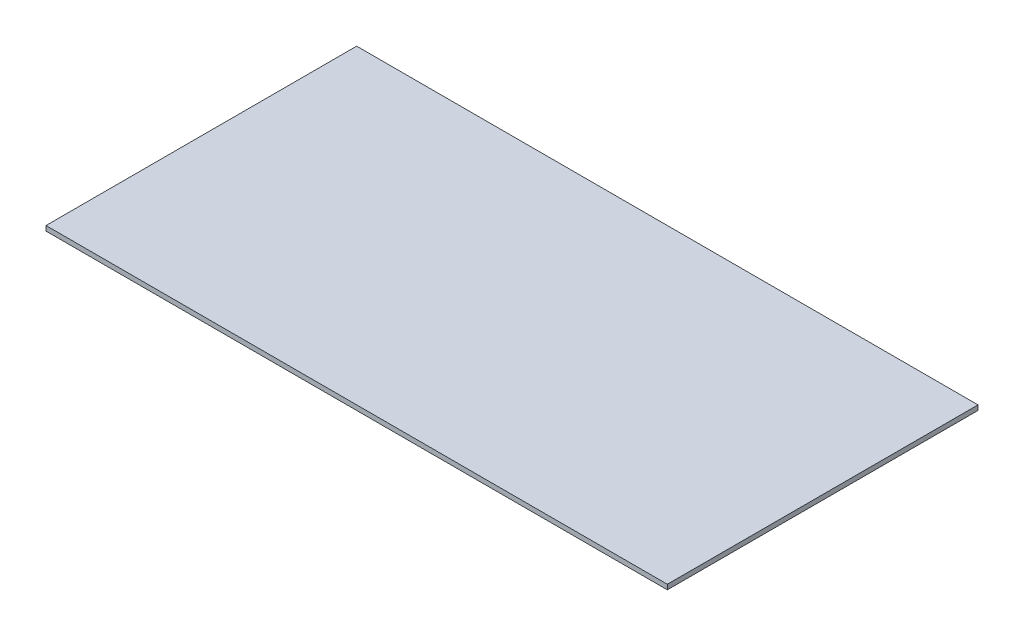
from build123d import *

# Parameters (mm, degrees)
SKETCH1_W           = 2438.4
SKETCH1_H           = 1219.2
BOSS_EXTRUDE1_DEPTH = 19.05


with BuildPart() as part:
    # Sketch1 → Boss-Extrude1 (new body)
    with BuildSketch(Plane(origin=(0, 0, 0), x_dir=(1, 0, 0), z_dir=(0, 1, 0))):
        Rectangle(SKETCH1_W, SKETCH1_H)
    extrude(amount=BOSS_EXTRUDE1_DEPTH)


solid = part.part
